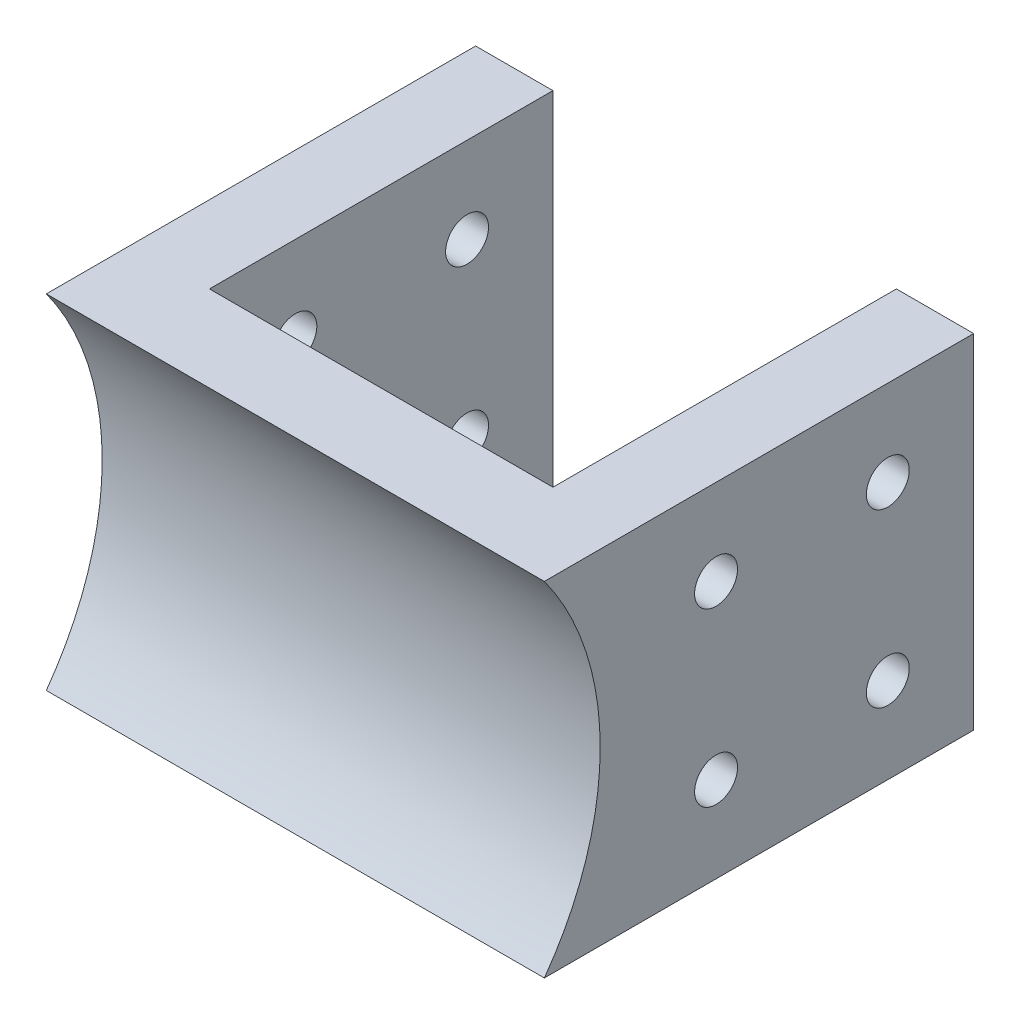
from build123d import *

# Parameters (mm, degrees)
BOSS_EXTRUDE1_DEPTH     = 40
SKETCH4_R               = 2.5
CUT_EXTRUDE1_DEPTH      = 50
CUT_EXTRUDE1_DEPTH_BACK = 10
CUT_EXTRUDE2_DEPTH      = 59


with BuildPart() as part:
    # Sketch1 → Boss-Extrude1 (new body)
    with BuildSketch(Plane(origin=(0, 0, 0), x_dir=(1, 0, 0), z_dir=(0, 1, 0))):
        Polygon((0, 0), (58, 0), (58, 50), (49, 50), (49, 10), (9, 10), (9, 50), (0, 50), align=None)
    extrude(amount=BOSS_EXTRUDE1_DEPTH)

    # Sketch4 → Cut-Extrude1 (cut, two sides)
    with BuildSketch(Plane.ZY.offset(-49)) as cut_extrude1_sk:
        with BuildLine():
            ThreePointArc((-42.5, 10), (-41.767766953, 8.232233047), (-40, 7.5))
            Line((-40, 7.5), (-40, 10))
            Line((-40, 10), (-42.5, 10))
        make_face()
        with BuildLine():
            Line((-40, 10), (-40, 7.5))
            ThreePointArc((-40, 7.5), (-38.232233047, 8.232233047), (-37.5, 10))
            ThreePointArc((-37.5, 10), (-40, 12.5), (-42.5, 10))
            Line((-42.5, 10), (-40, 10))
        make_face()
        with Locations((-20, 10)):
            Circle(SKETCH4_R)
        with Locations((-40, 30)):
            Circle(SKETCH4_R)
        with Locations((-20, 30)):
            Circle(SKETCH4_R)
    extrude(amount=CUT_EXTRUDE1_DEPTH, mode=Mode.SUBTRACT)
    extrude(cut_extrude1_sk.sketch, amount=-CUT_EXTRUDE1_DEPTH_BACK, mode=Mode.SUBTRACT)

    # Sketch5 → Cut-Extrude2 (cut, through all)
    with BuildSketch(Plane(origin=(58, 0, 0), x_dir=(0, 0, -1), z_dir=(1, 0, 0))):
        with BuildLine():
            Line((0, 40), (0, 0))
            ThreePointArc((0, 0), (6.50454583, 20), (0, 40))
        make_face()
    extrude(amount=-CUT_EXTRUDE2_DEPTH, mode=Mode.SUBTRACT)


solid = part.part
